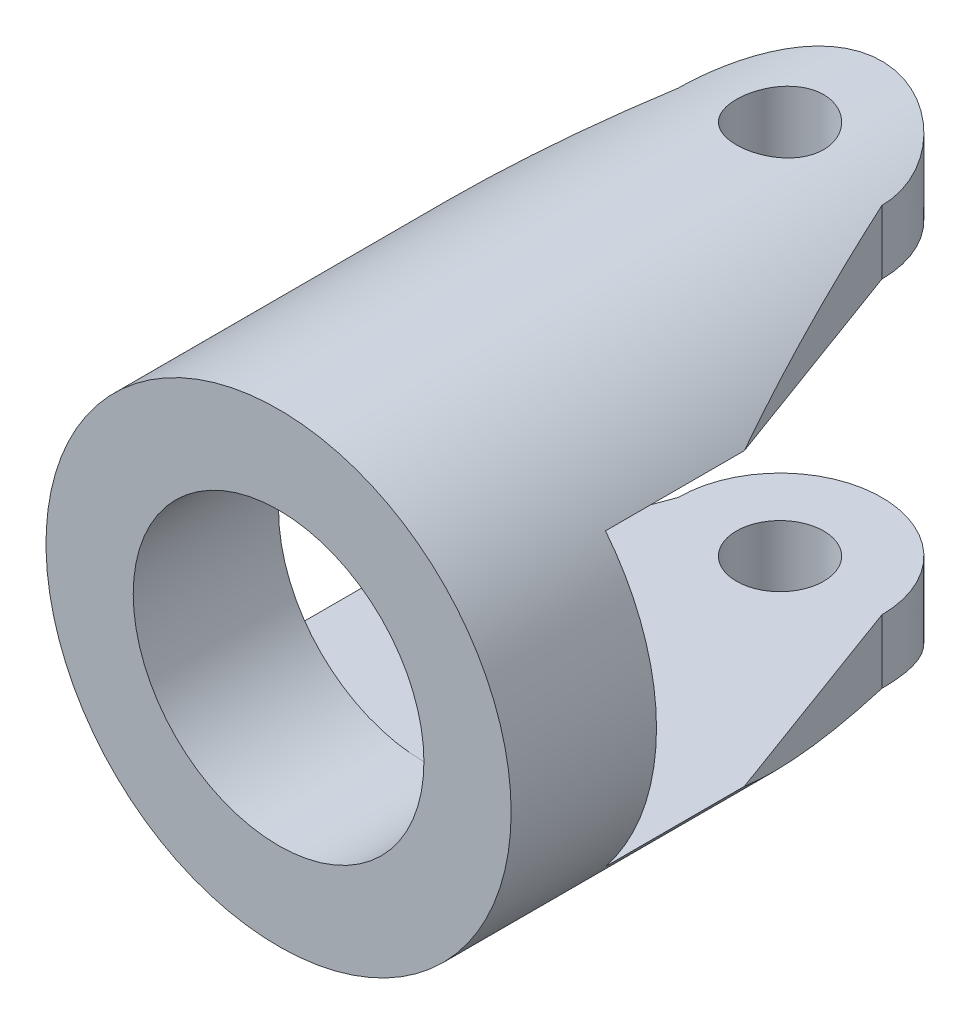
from build123d import *

# Parameters (mm, degrees)
SKETCH1_R               = 8
SKETCH1_R_2             = 5
BOSS_EXTRUDE1_DEPTH     = 20.75
SKETCH2_R               = 1.5
CUT_EXTRUDE1_DEPTH      = 9
CUT_EXTRUDE1_DEPTH_BACK = 9
SKETCH4_W               = 15.75
SKETCH4_H               = 10
CUT_EXTRUDE2_DEPTH      = 9.0000001
CUT_EXTRUDE2_DEPTH_BACK = 9.0000001


with BuildPart() as part:
    # Sketch1 → Boss-Extrude1 (new body)
    with BuildSketch(Plane.XY):
        Circle(SKETCH1_R)
        Circle(SKETCH1_R_2, mode=Mode.SUBTRACT)
    extrude(amount=BOSS_EXTRUDE1_DEPTH)

    # Sketch2 → Cut-Extrude1 (cut, two sides)
    with BuildSketch(Plane(origin=(0, 0, 0), x_dir=(1, 0, 0), z_dir=(0, 1, 0))) as cut_extrude1_sk:
        with Locations((0, -3.5)):
            Circle(SKETCH2_R)
        with BuildLine():
            Line((-8, -15.75), (-8, 2.25))
            Line((-8, 2.25), (8, 2.25))
            Line((8, 2.25), (8, -15.75))
            Line((8, -15.75), (3.5, -3.5))
            ThreePointArc((3.5, -3.5), (0, 0), (-3.5, -3.5))
            Line((-3.5, -3.5), (-8, -15.75))
        make_face()
    extrude(amount=CUT_EXTRUDE1_DEPTH, mode=Mode.SUBTRACT)
    extrude(cut_extrude1_sk.sketch, amount=-CUT_EXTRUDE1_DEPTH_BACK, mode=Mode.SUBTRACT)

    # Sketch4 → Cut-Extrude2 (cut, two sides)
    with BuildSketch(Plane(origin=(0, 0, 0), x_dir=(0, 0, -1), z_dir=(1, 0, 0))) as cut_extrude2_sk:
        with Locations((-7.875, 0)):
            Rectangle(SKETCH4_W, SKETCH4_H)
    extrude(amount=CUT_EXTRUDE2_DEPTH, mode=Mode.SUBTRACT)
    extrude(cut_extrude2_sk.sketch, amount=-CUT_EXTRUDE2_DEPTH_BACK, mode=Mode.SUBTRACT)


solid = part.part
